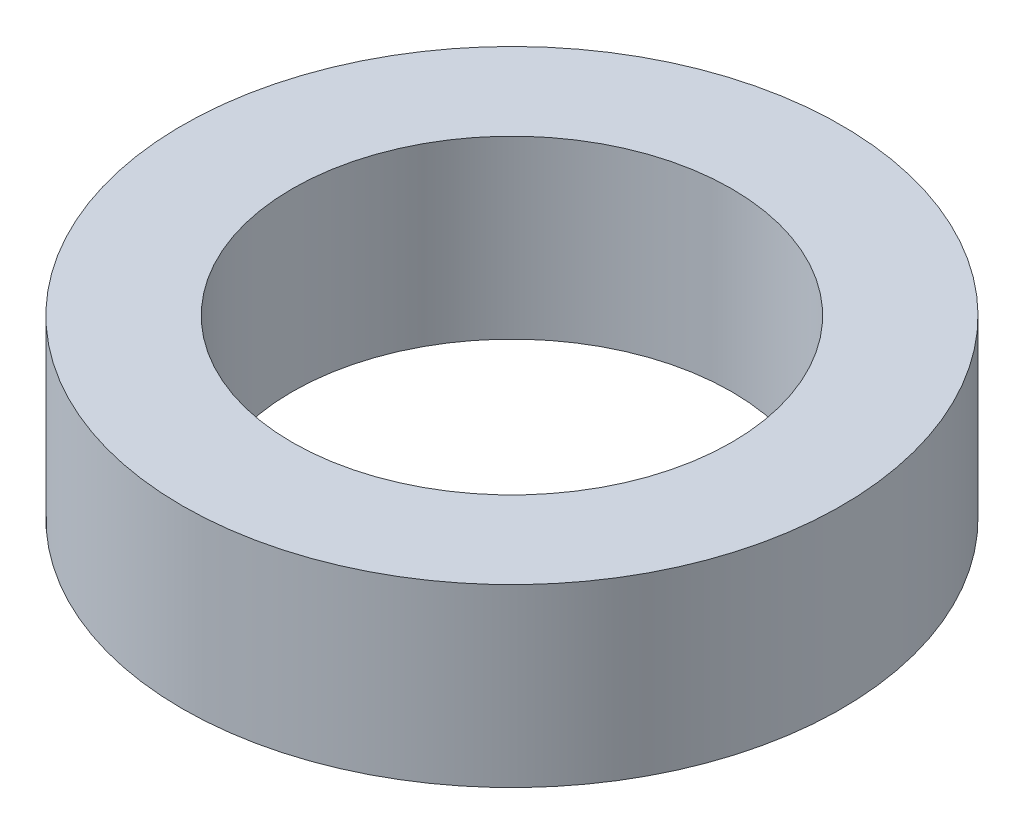
from build123d import *

# Parameters (mm, degrees)
SKETCH1_R           = 7.5
SKETCH1_R_2         = 5
BOSS_EXTRUDE1_DEPTH = 2


with BuildPart() as part:
    # Sketch1 → Boss-Extrude1 (new body, symmetric)
    with BuildSketch(Plane(origin=(0, 0, 0), x_dir=(1, 0, 0), z_dir=(0, 1, 0))):
        Circle(SKETCH1_R)
        Circle(SKETCH1_R_2, mode=Mode.SUBTRACT)
    extrude(amount=BOSS_EXTRUDE1_DEPTH, both=True)


solid = part.part
